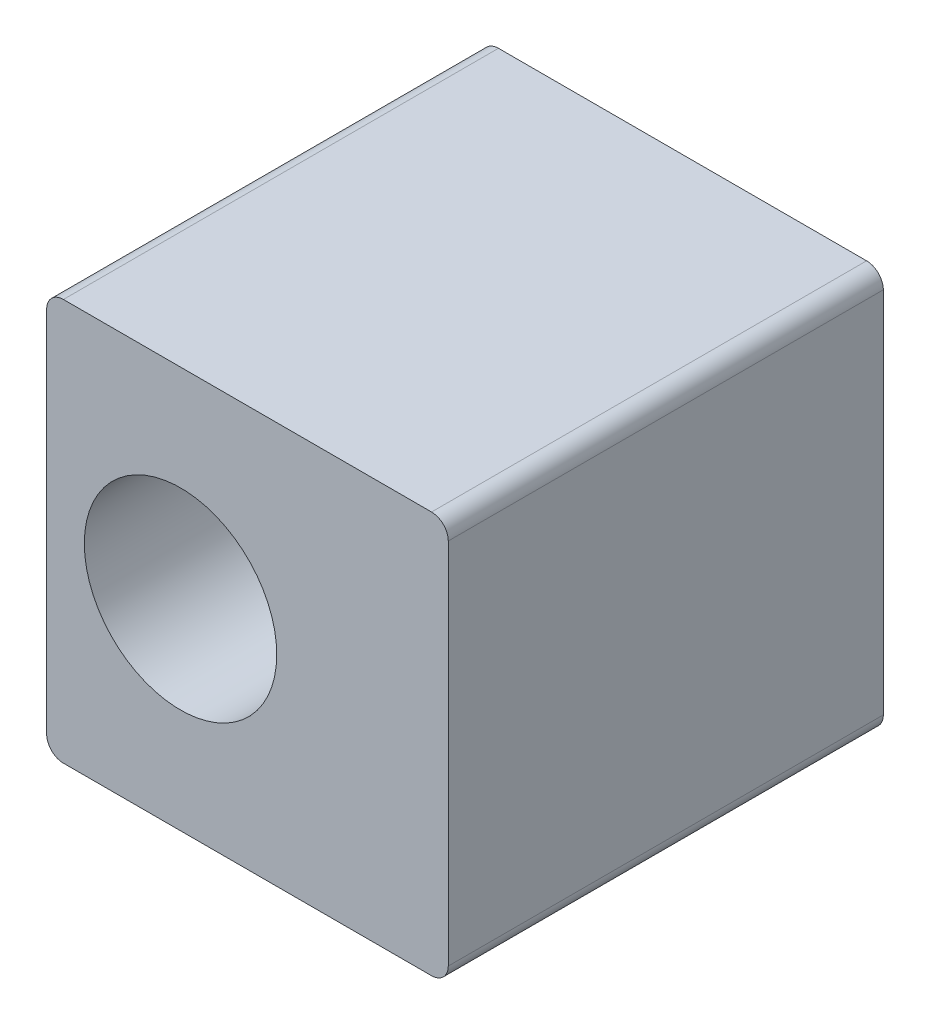
from build123d import *

# Parameters (mm, degrees)
SKETCH1_R           = 2.875
BOSS_EXTRUDE1_DEPTH = 5
BOSS_EXTRUDE3_DEPTH = 8
FILLET1_R           = 0.5
SKETCH2_W           = 1.6
SKETCH2_H           = 11.5
CUT_EXTRUDE1_DEPTH  = 6
BOSS_EXTRUDE4_REACH = 18.492


with BuildPart() as part:
    # Sketch1 → Boss-Extrude1 (new body)
    with BuildSketch(Plane.XY):
        Polygon((-4, 0), (-4, -6), (8, -6), (8, 6), (-4, 6), align=None)
        Circle(SKETCH1_R, mode=Mode.SUBTRACT)
    extrude(amount=BOSS_EXTRUDE1_DEPTH)

    # Sketch1_4 → Boss-Extrude3 (add)
    with BuildSketch(Plane.XY):
        with BuildLine():
            ThreePointArc((4.5, 0), (1.060660172, -4.373213921), (-4, -2.061552813))
            Line((-4, -2.061552813), (-4, -6))
            Line((-4, -6), (8, -6))
            Line((8, -6), (8, 6))
            Line((8, 6), (-4, 6))
            Line((-4, 6), (-4, 2.061552813))
            ThreePointArc((-4, 2.061552813), (1.060660172, 4.373213921), (4.5, 0))
        make_face()
    extrude(amount=-BOSS_EXTRUDE3_DEPTH)

    # Fillet1
    fillet1_edges = [part.edges().sort_by_distance(p)[0] for p in [
        (-4, 6, -1.5),
        (8, 6, -1.5),
        (8, -6, -1.5),
        (-4, -6, -1.5),
        (-4, 2.061552813, -4),
        (-4, -2.061552813, -4),
    ]]
    fillet(fillet1_edges, radius=FILLET1_R)

    # Sketch2 → Cut-Extrude1 (cut)
    with BuildSketch(Plane.XZ.offset(6)):
        with Locations((5.7, -2.25)):
            Rectangle(SKETCH2_W, SKETCH2_H)
    extrude(amount=-CUT_EXTRUDE1_DEPTH, mode=Mode.SUBTRACT)

    # Sketch3 → Boss-Extrude4 (add, up to next)
    with BuildSketch(Plane.XZ.offset(6), mode=Mode.PRIVATE) as boss_extrude4_sk1:
        with BuildLine():
            Line((4.9, -8), (5.05, -8))
            ThreePointArc((5.05, -8), (5.65, -7.4), (5.05, -6.8))
            Line((5.05, -6.8), (4.9, -6.8))
            Line((4.9, -6.8), (4.9, -8))
        make_face()
    boss_extrude4_tool1 = extrude(boss_extrude4_sk1.sketch, amount=-BOSS_EXTRUDE4_REACH, mode=Mode.PRIVATE) - part.part
    # Sketch3 → Boss-Extrude4 (add, up to next)
    with BuildSketch(Plane.XZ.offset(6), mode=Mode.PRIVATE) as boss_extrude4_sk2:
        with BuildLine():
            Line((5.05, -4.8), (4.9, -4.8))
            Line((4.9, -4.8), (4.9, -6))
            Line((4.9, -6), (5.05, -6))
            ThreePointArc((5.05, -6), (5.65, -5.4), (5.05, -4.8))
        make_face()
    boss_extrude4_tool2 = extrude(boss_extrude4_sk2.sketch, amount=-BOSS_EXTRUDE4_REACH, mode=Mode.PRIVATE) - part.part
    # Sketch3 → Boss-Extrude4 (add, up to next)
    with BuildSketch(Plane.XZ.offset(6), mode=Mode.PRIVATE) as boss_extrude4_sk3:
        with BuildLine():
            Line((5.05, -2.8), (4.9, -2.8))
            Line((4.9, -2.8), (4.9, -4))
            Line((4.9, -4), (5.05, -4))
            ThreePointArc((5.05, -4), (5.65, -3.4), (5.05, -2.8))
        make_face()
    boss_extrude4_tool3 = extrude(boss_extrude4_sk3.sketch, amount=-BOSS_EXTRUDE4_REACH, mode=Mode.PRIVATE) - part.part
    # Sketch3 → Boss-Extrude4 (add, up to next)
    with BuildSketch(Plane.XZ.offset(6), mode=Mode.PRIVATE) as boss_extrude4_sk4:
        with BuildLine():
            Line((5.05, -0.8), (4.9, -0.8))
            Line((4.9, -0.8), (4.9, -2))
            Line((4.9, -2), (5.05, -2))
            ThreePointArc((5.05, -2), (5.65, -1.4), (5.05, -0.8))
        make_face()
    boss_extrude4_tool4 = extrude(boss_extrude4_sk4.sketch, amount=-BOSS_EXTRUDE4_REACH, mode=Mode.PRIVATE) - part.part
    # Sketch3 → Boss-Extrude4 (add, up to next)
    with BuildSketch(Plane.XZ.offset(6), mode=Mode.PRIVATE) as boss_extrude4_sk5:
        with BuildLine():
            Line((5.05, 1.2), (4.9, 1.2))
            Line((4.9, 1.2), (4.9, 0))
            Line((4.9, 0), (5.05, 0))
            ThreePointArc((5.05, 0), (5.65, 0.6), (5.05, 1.2))
        make_face()
    boss_extrude4_tool5 = extrude(boss_extrude4_sk5.sketch, amount=-BOSS_EXTRUDE4_REACH, mode=Mode.PRIVATE) - part.part
    # Sketch3 → Boss-Extrude4 (add, up to next)
    with BuildSketch(Plane.XZ.offset(6), mode=Mode.PRIVATE) as boss_extrude4_sk6:
        with BuildLine():
            Line((5.05, 3.2), (4.9, 3.2))
            Line((4.9, 3.2), (4.9, 2))
            Line((4.9, 2), (5.05, 2))
            ThreePointArc((5.05, 2), (5.65, 2.6), (5.05, 3.2))
        make_face()
    boss_extrude4_tool6 = extrude(boss_extrude4_sk6.sketch, amount=-BOSS_EXTRUDE4_REACH, mode=Mode.PRIVATE) - part.part
    add(boss_extrude4_tool1.solids().sort_by_distance((5.225053, -6, -7.4))[0])
    add(boss_extrude4_tool2.solids().sort_by_distance((5.225053, -6, -5.4))[0])
    add(boss_extrude4_tool3.solids().sort_by_distance((5.225053, -6, -3.4))[0])
    add(boss_extrude4_tool4.solids().sort_by_distance((5.225053, -6, -1.4))[0])
    add(boss_extrude4_tool5.solids().sort_by_distance((5.225053, -6, 0.6))[0])
    add(boss_extrude4_tool6.solids().sort_by_distance((5.225053, -6, 2.6))[0])


solid = part.part
